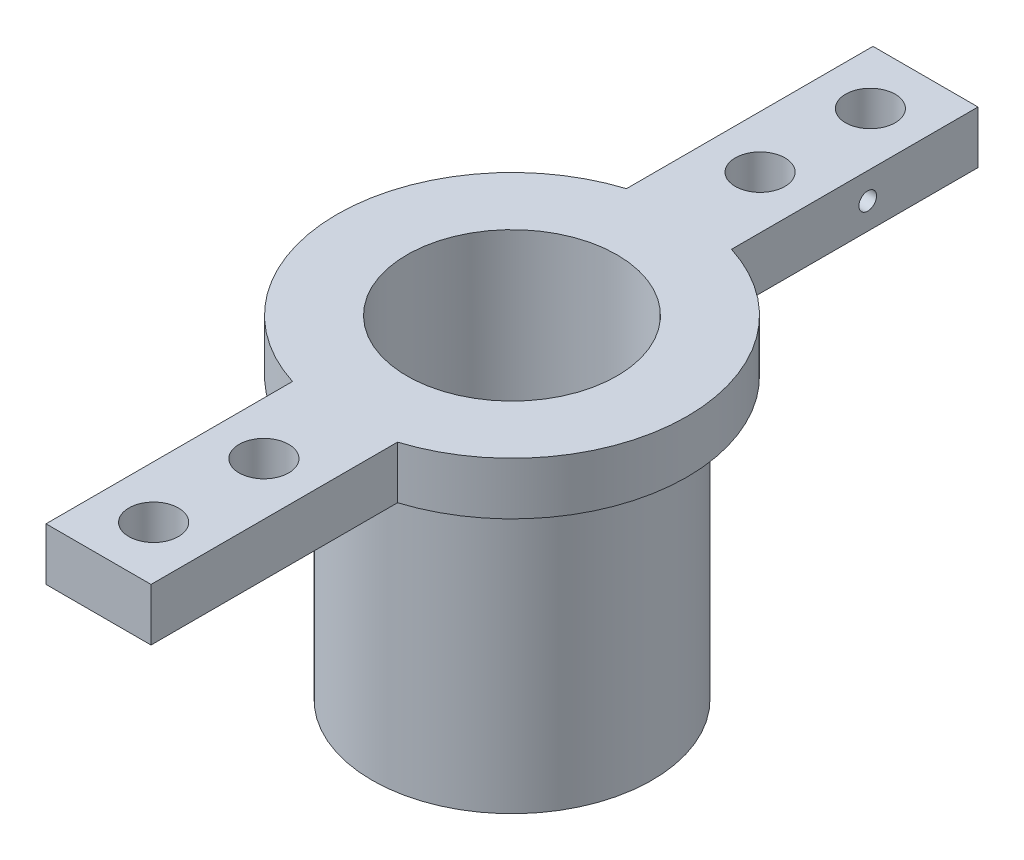
from build123d import *

# Parameters (mm, degrees)
SKETCH2_R             = 12.7
SKETCH2_R_2           = 9.525
BOSS_EXTRUDE1_DEPTH   = 12.7
SKETCH3_R             = 12.7
BOSS_EXTRUDE2_DEPTH   = 4.7625
SKETCH4_R             = 9.525
CUT_EXTRUDE1_DEPTH    = 5.7625
M4_CLEARANCE_HOLE1_D  = 4.5
M2X0_4_TAPPED_HOLE1_D = 1.6


with BuildPart() as part:
    # Sketch2 → Boss-Extrude1 (new body, symmetric)
    with BuildSketch(Plane(origin=(0, 0, 0), x_dir=(1, 0, 0), z_dir=(0, 1, 0))):
        Circle(SKETCH2_R)
        Circle(SKETCH2_R_2, mode=Mode.SUBTRACT)
    extrude(amount=BOSS_EXTRUDE1_DEPTH, both=True)

    # Sketch3 → Boss-Extrude2 (add)
    with BuildSketch(Plane(origin=(0, 12.7, 0), x_dir=(1, 0, 0), z_dir=(0, 1, 0))):
        with BuildLine():
            ThreePointArc((-4.7625, -15.143784822), (0, -15.875), (4.7625, -15.143784822))
            Line((4.7625, -15.143784822), (4.7625, -11.773215098))
            ThreePointArc((4.7625, -11.773215098), (0, -12.7), (-4.7625, -11.773215098))
            Line((-4.7625, -11.773215098), (-4.7625, -15.143784822))
        make_face()
        with BuildLine():
            ThreePointArc((4.7625, 15.143784822), (0, 15.875), (-4.7625, 15.143784822))
            Line((-4.7625, 15.143784822), (-4.7625, 11.773215098))
            ThreePointArc((-4.7625, 11.773215098), (0, 12.7), (4.7625, 11.773215098))
            Line((4.7625, 11.773215098), (4.7625, 15.143784822))
        make_face()
        with BuildLine():
            Line((-4.7625, -37.5), (4.7625, -37.5))
            Line((4.7625, -37.5), (4.7625, -15.143784822))
            ThreePointArc((4.7625, -15.143784822), (0, -15.875), (-4.7625, -15.143784822))
            Line((-4.7625, -15.143784822), (-4.7625, -37.5))
        make_face()
        with BuildLine():
            Line((-4.7625, 37.5), (-4.7625, 15.143784822))
            ThreePointArc((-4.7625, 15.143784822), (0, 15.875), (4.7625, 15.143784822))
            Line((4.7625, 15.143784822), (4.7625, 37.5))
            Line((4.7625, 37.5), (-4.7625, 37.5))
        make_face()
        with BuildLine():
            Line((4.7625, -11.773215098), (4.7625, -15.143784822))
            ThreePointArc((4.7625, -15.143784822), (12.798834175, -9.391776656), (15.875, 0))
            ThreePointArc((15.875, 0), (12.798834175, 9.391776656), (4.7625, 15.143784822))
            Line((4.7625, 15.143784822), (4.7625, 11.773215098))
            ThreePointArc((4.7625, 11.773215098), (10.530283709, 7.099515829), (12.7, 0))
            ThreePointArc((12.7, 0), (10.530283709, -7.099515829), (4.7625, -11.773215098))
        make_face()
        with BuildLine():
            ThreePointArc((-4.7625, 15.143784822), (-15.875, 0), (-4.7625, -15.143784822))
            Line((-4.7625, -15.143784822), (-4.7625, -11.773215098))
            ThreePointArc((-4.7625, -11.773215098), (-12.7, 0), (-4.7625, 11.773215098))
            Line((-4.7625, 11.773215098), (-4.7625, 15.143784822))
        make_face()
        Circle(SKETCH3_R)
    extrude(amount=BOSS_EXTRUDE2_DEPTH)

    # Sketch4 → Cut-Extrude1 (cut, through all)
    with BuildSketch(Plane.XZ.offset(-12.7)):
        Circle(SKETCH4_R)
    extrude(amount=-CUT_EXTRUDE1_DEPTH, mode=Mode.SUBTRACT)

    # M4 Clearance Hole1 (through all)
    with Locations(Plane(origin=(0, 12.7, 0), x_dir=(-1, 0, 0), z_dir=(0, -1, 0))):
        with Locations((0, 32.5), (0, 22.5), (0, -22.5), (0, -32.5)):
            Hole(M4_CLEARANCE_HOLE1_D / 2)

    # M2x0.4 Tapped Hole1 (through all)
    with Locations(Plane(origin=(4.7625, 0, 0), x_dir=(0, 0, -1), z_dir=(1, 0, 0))):
        with Locations((27.5, 15.08125)):
            Hole(M2X0_4_TAPPED_HOLE1_D / 2)


solid = part.part
